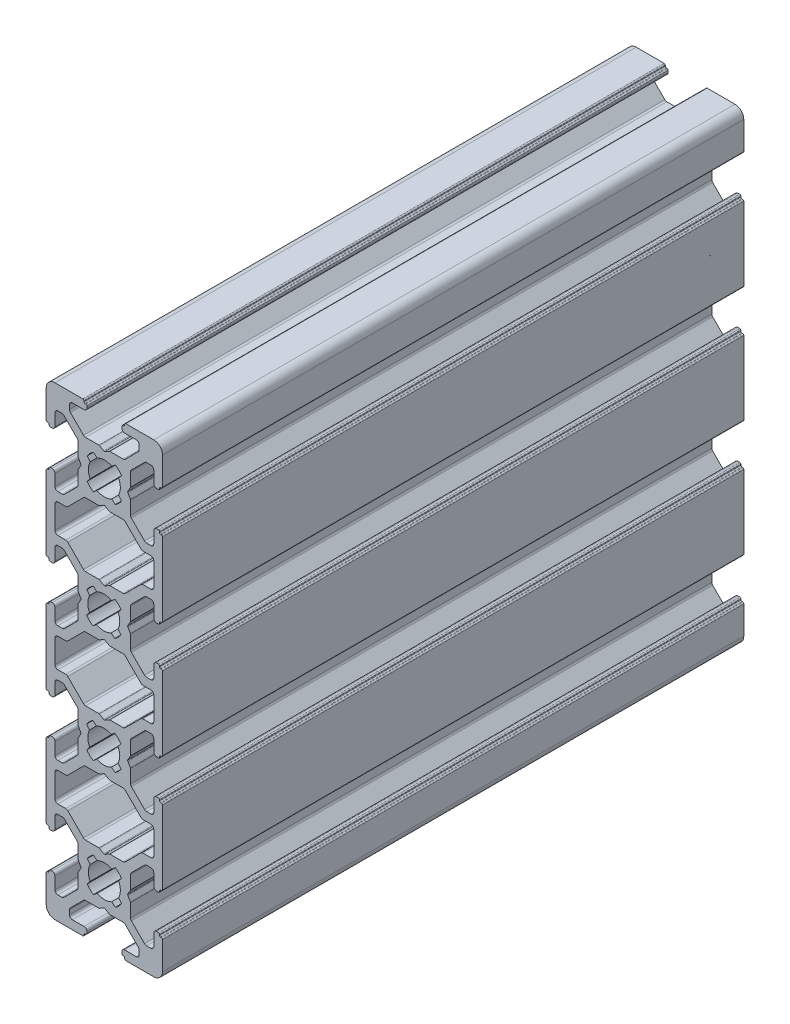
from build123d import *

# Parameters (mm, degrees)
EXTRUDE_1_DEPTH = 100


with BuildPart() as part:
    # Эскиз1 → Бобышка-Вытянуть1 (new body)
    with BuildSketch(Plane.XY):
        with BuildLine():
            Line((4.499999535, -3.232230546), (4.499999535, -0.95359075))
            ThreePointArc((4.499999535, -0.95359075), (4.4931847, -0.901826942), (4.473204617, -0.853590752))
            Line((4.473204617, -0.853590752), (4.038119091, -0.100000495))
            ThreePointArc((4.038119091, -0.100000495), (4.01132417, -4.91e-07), (4.038119086, 0.099999515))
            Line((4.038119086, 0.099999515), (4.473204622, 0.853589873))
            ThreePointArc((4.473204622, 0.853589873), (4.493184702, 0.901826059), (4.499999535, 0.953589862))
            Line((4.499999535, 0.953589862), (4.499999535, 3.232229658))
            ThreePointArc((4.499999535, 3.232229658), (4.538059693, 3.423571193), (4.646445866, 3.585782771))
            Line((4.646445866, 3.585782771), (6.914212891, 5.853553365))
            ThreePointArc((6.914212891, 5.853553365), (7.076424662, 5.961939944), (7.26776656, 6.000000253))
            Line((7.26776656, 6.000000253), (7.99999922, 6.000000253))
            ThreePointArc((7.99999922, 6.000000253), (8.353552705, 5.853553604), (8.499999354, 5.500000119))
            Line((8.499999354, 5.500000119), (8.499999354, 3.499999514))
            ThreePointArc((8.499999354, 3.499999514), (8.646445963, 3.146446123), (8.999999354, 2.999999514))
            Line((8.999999354, 2.999999514), (9.299998864, 2.999999514))
            ThreePointArc((9.299998864, 2.999999514), (9.44142022, 3.058578158), (9.499998864, 3.199999514))
            Line((9.499998864, 3.199999514), (9.499998864, 3.299999514))
            ThreePointArc((9.499998864, 3.299999514), (9.558577631, 3.441420994), (9.699999215, 3.499999514))
            Line((9.699999215, 3.499999514), (9.799999215, 3.499999339))
            ThreePointArc((9.799999215, 3.499999339), (9.941420798, 3.558577858), (9.999999566, 3.699999339))
            Line((9.999999566, 3.699999339), (9.999999566, 9.999999514))
            Line((9.999999566, 9.999999514), (9.999999566, 16.349999199))
            ThreePointArc((9.999999566, 16.349999199), (9.941420922, 16.491420555), (9.799999566, 16.549999199))
            Line((9.799999566, 16.549999199), (9.699999566, 16.549999199))
            ThreePointArc((9.699999566, 16.549999199), (9.558578154, 16.608577898), (9.499999566, 16.749999356))
            Line((9.499999566, 16.749999356), (9.499999645, 16.849999356))
            ThreePointArc((9.499999645, 16.849999356), (9.441421057, 16.991420815), (9.299999645, 17.049999514))
            Line((9.299999645, 17.049999514), (9.000000135, 17.049999514))
            ThreePointArc((9.000000135, 17.049999514), (8.646446744, 16.903552905), (8.500000135, 16.549999514))
            Line((8.500000135, 16.549999514), (8.500000135, 14.500000172))
            ThreePointArc((8.500000135, 14.500000172), (8.353553486, 14.146446686), (8.000000001, 14.000000038))
            Line((8.000000001, 14.000000038), (7.267765297, 14.000000038))
            ThreePointArc((7.267765297, 14.000000038), (7.076423399, 14.038060347), (6.914211628, 14.146446925))
            Line((6.914211628, 14.146446925), (4.646445866, 16.414216257))
            ThreePointArc((4.646445866, 16.414216257), (4.538059693, 16.576427835), (4.499999535, 16.76776937))
            Line((4.499999535, 16.76776937), (4.499999535, 19.046409166))
            ThreePointArc((4.499999535, 19.046409166), (4.493184702, 19.098172969), (4.473204622, 19.146409155))
            Line((4.473204622, 19.146409155), (4.038119086, 19.899999513))
            ThreePointArc((4.038119086, 19.899999513), (4.018139004, 19.948235705), (4.01132417, 19.999999514))
            ThreePointArc((4.01132417, 19.999999514), (4.018139004, 20.051763323), (4.038119086, 20.099999515))
            Line((4.038119086, 20.099999515), (4.473204615, 20.853589862))
            ThreePointArc((4.473204615, 20.853589862), (4.493184695, 20.901826048), (4.499999528, 20.953589851))
            Line((4.499999528, 20.953589851), (4.499999528, 23.232229647))
            ThreePointArc((4.499999528, 23.232229647), (4.538059687, 23.423571182), (4.64644586, 23.58578276))
            Line((4.64644586, 23.58578276), (6.914212884, 25.853553354))
            ThreePointArc((6.914212884, 25.853553354), (7.076424655, 25.961939932), (7.267766553, 26.000000241))
            Line((7.267766553, 26.000000241), (7.99999922, 26.000000241))
            ThreePointArc((7.99999922, 26.000000241), (8.353552705, 25.853553593), (8.499999354, 25.500000107))
            Line((8.499999354, 25.500000107), (8.499999354, 23.499999514))
            ThreePointArc((8.499999354, 23.499999514), (8.646445963, 23.146446123), (8.999999354, 22.999999514))
            Line((8.999999354, 22.999999514), (9.299998864, 22.999999514))
            ThreePointArc((9.299998864, 22.999999514), (9.44142022, 23.058578158), (9.499998864, 23.199999514))
            Line((9.499998864, 23.199999514), (9.499998864, 23.299999514))
            ThreePointArc((9.499998864, 23.299999514), (9.558577631, 23.441420994), (9.699999215, 23.499999514))
            Line((9.699999215, 23.499999514), (9.799999215, 23.499999339))
            ThreePointArc((9.799999215, 23.499999339), (9.941420798, 23.558577858), (9.999999566, 23.699999339))
            Line((9.999999566, 23.699999339), (9.999999566, 36.300000176))
            ThreePointArc((9.999999566, 36.300000176), (9.941420798, 36.441421656), (9.799999215, 36.500000176))
            Line((9.799999215, 36.500000176), (9.699999215, 36.5))
            ThreePointArc((9.699999215, 36.5), (9.558577631, 36.55857852), (9.499998864, 36.7))
            Line((9.499998864, 36.7), (9.499998864, 36.8))
            ThreePointArc((9.499998864, 36.8), (9.44142022, 36.941421356), (9.299998864, 37))
            Line((9.299998864, 37), (8.999999354, 37))
            ThreePointArc((8.999999354, 37), (8.646445963, 36.853553391), (8.499999354, 36.5))
            Line((8.499999354, 36.5), (8.499999354, 34.499999407))
            ThreePointArc((8.499999354, 34.499999407), (8.353552705, 34.146445921), (7.99999922, 33.999999273))
            Line((7.99999922, 33.999999273), (7.267766553, 33.999999273))
            ThreePointArc((7.267766553, 33.999999273), (7.076424655, 34.038059582), (6.914212884, 34.14644616))
            Line((6.914212884, 34.14644616), (4.64644586, 36.414216754))
            ThreePointArc((4.64644586, 36.414216754), (4.538059687, 36.576428332), (4.499999528, 36.767769867))
            Line((4.499999528, 36.767769867), (4.499999528, 39.046409663))
            ThreePointArc((4.499999528, 39.046409663), (4.493184695, 39.098173466), (4.473204615, 39.146409652))
            Line((4.473204615, 39.146409652), (4.038119086, 39.899999999))
            ThreePointArc((4.038119086, 39.899999999), (4.018139004, 39.948236191), (4.01132417, 40))
            ThreePointArc((4.01132417, 40), (4.018139004, 40.051763809), (4.038119086, 40.100000001))
            Line((4.038119086, 40.100000001), (4.473204622, 40.853590359))
            ThreePointArc((4.473204622, 40.853590359), (4.493184702, 40.901826545), (4.499999535, 40.953590348))
            Line((4.499999535, 40.953590348), (4.499999535, 43.232230144))
            ThreePointArc((4.499999535, 43.232230144), (4.538059693, 43.423571679), (4.646445866, 43.585783257))
            Line((4.646445866, 43.585783257), (6.914211628, 45.853552589))
            ThreePointArc((6.914211628, 45.853552589), (7.076423399, 45.961939167), (7.267765297, 45.999999476))
            Line((7.267765297, 45.999999476), (8.000000001, 45.999999476))
            ThreePointArc((8.000000001, 45.999999476), (8.353553486, 45.853552828), (8.500000135, 45.499999342))
            Line((8.500000135, 45.499999342), (8.500000135, 43.45))
            ThreePointArc((8.500000135, 43.45), (8.646446744, 43.096446609), (9.000000135, 42.95))
            Line((9.000000135, 42.95), (9.299999645, 42.95))
            ThreePointArc((9.299999645, 42.95), (9.441421057, 43.0085787), (9.499999645, 43.150000158))
            Line((9.499999645, 43.150000158), (9.499999566, 43.250000158))
            ThreePointArc((9.499999566, 43.250000158), (9.558578154, 43.391421616), (9.699999566, 43.450000315))
            Line((9.699999566, 43.450000315), (9.799999566, 43.450000315))
            ThreePointArc((9.799999566, 43.450000315), (9.941420922, 43.508578959), (9.999999566, 43.650000315))
            Line((9.999999566, 43.650000315), (9.999999566, 50))
            Line((9.999999566, 50), (9.999999566, 56.300000176))
            ThreePointArc((9.999999566, 56.300000176), (9.941420798, 56.441421656), (9.799999215, 56.500000176))
            Line((9.799999215, 56.500000176), (9.699999215, 56.5))
            ThreePointArc((9.699999215, 56.5), (9.558577631, 56.55857852), (9.499998864, 56.7))
            Line((9.499998864, 56.7), (9.499998864, 56.8))
            ThreePointArc((9.499998864, 56.8), (9.44142022, 56.941421356), (9.299998864, 57))
            Line((9.299998864, 57), (8.999999354, 57))
            ThreePointArc((8.999999354, 57), (8.646445963, 56.853553391), (8.499999354, 56.5))
            Line((8.499999354, 56.5), (8.499999354, 54.499999395))
            ThreePointArc((8.499999354, 54.499999395), (8.353552705, 54.14644591), (7.99999922, 53.999999261))
            Line((7.99999922, 53.999999261), (7.26776656, 53.999999261))
            ThreePointArc((7.26776656, 53.999999261), (7.076424662, 54.03805957), (6.914212891, 54.146446149))
            Line((6.914212891, 54.146446149), (4.646445866, 56.414216743))
            ThreePointArc((4.646445866, 56.414216743), (4.538059693, 56.576428321), (4.499999535, 56.767769856))
            Line((4.499999535, 56.767769856), (4.499999535, 59.046409652))
            ThreePointArc((4.499999535, 59.046409652), (4.493184702, 59.098173455), (4.473204622, 59.146409641))
            Line((4.473204622, 59.146409641), (4.038119086, 59.899999999))
            ThreePointArc((4.038119086, 59.899999999), (4.01132417, 60.000000005), (4.038119091, 60.100000009))
            Line((4.038119091, 60.100000009), (4.473204617, 60.853590266))
            ThreePointArc((4.473204617, 60.853590266), (4.4931847, 60.901826456), (4.499999535, 60.953590264))
            Line((4.499999535, 60.953590264), (4.499999535, 63.23223006))
            ThreePointArc((4.499999535, 63.23223006), (4.538059689, 63.423571583), (4.646445849, 63.585783155))
            Line((4.646445849, 63.585783155), (6.91421126, 65.853552357))
            ThreePointArc((6.91421126, 65.853552357), (7.076423037, 65.961938948), (7.267764946, 65.999999261))
            Line((7.267764946, 65.999999261), (7.999999354, 65.999999261))
            ThreePointArc((7.999999354, 65.999999261), (8.353552744, 65.853552652), (8.499999354, 65.499999261))
            Line((8.499999354, 65.499999261), (8.499999354, 63.5))
            ThreePointArc((8.499999354, 63.5), (8.646445963, 63.146446609), (8.999999354, 63))
            Line((8.999999354, 63), (9.299998864, 63))
            ThreePointArc((9.299998864, 63), (9.44142022, 63.058578644), (9.499998864, 63.2))
            Line((9.499998864, 63.2), (9.499998864, 63.3))
            ThreePointArc((9.499998864, 63.3), (9.558577631, 63.44142148), (9.699999215, 63.5))
            Line((9.699999215, 63.5), (9.799999215, 63.499999824))
            ThreePointArc((9.799999215, 63.499999824), (9.941420798, 63.558578344), (9.999999566, 63.699999824))
            Line((9.999999566, 63.699999824), (9.999999566, 68.500000027))
            ThreePointArc((9.999999566, 68.500000027), (9.560659745, 69.56066018), (8.499999593, 70))
            Line((8.499999593, 70), (3.699999104, 70))
            ThreePointArc((3.699999104, 70), (3.558577748, 69.941421356), (3.499999104, 69.8))
            Line((3.499999104, 69.8), (3.499999104, 69.7))
            ThreePointArc((3.499999104, 69.7), (3.441420542, 69.558578725), (3.299999335, 69.5))
            Line((3.299999335, 69.5), (3.199999335, 69.499999885))
            ThreePointArc((3.199999335, 69.499999885), (3.058578128, 69.441421159), (2.999999566, 69.299999885))
            Line((2.999999566, 69.299999885), (2.999999566, 69.000001846))
            ThreePointArc((2.999999566, 69.000001846), (3.146446175, 68.646448455), (3.499999566, 68.500001846))
            Line((3.499999566, 68.500001846), (5.499999432, 68.500001846))
            ThreePointArc((5.499999432, 68.500001846), (5.853552917, 68.353555197), (5.999999566, 68.000001712))
            Line((5.999999566, 68.000001712), (5.999999566, 67.267766328))
            ThreePointArc((5.999999566, 67.267766328), (5.961940007, 67.076426242), (5.853555452, 66.914215433))
            Line((5.853555452, 66.914215433), (3.585869317, 64.646497282))
            ThreePointArc((3.585869317, 64.646497282), (3.423656777, 64.538109086), (3.23231343, 64.500048177))
            Line((3.23231343, 64.500048177), (0.953673634, 64.500048177))
            ThreePointArc((0.953673634, 64.500048177), (0.901909826, 64.493233342), (0.853673636, 64.473253259))
            Line((0.853673636, 64.473253259), (0.099999543, 64.03811933))
            ThreePointArc((0.099999543, 64.03811933), (-4.69e-07, 64.011324409), (-0.100000481, 64.038119334))
            Line((-0.100000481, 64.038119334), (-0.853674499, 64.473253255))
            ThreePointArc((-0.853674499, 64.473253255), (-0.901910692, 64.493233342), (-0.953674503, 64.500048177))
            Line((-0.953674503, 64.500048177), (-3.232314299, 64.500048177))
            ThreePointArc((-3.232314299, 64.500048177), (-3.423657646, 64.538109086), (-3.585870185, 64.646497282))
            Line((-3.585870185, 64.646497282), (-5.853556321, 66.914215433))
            ThreePointArc((-5.853556321, 66.914215433), (-5.961940876, 67.076426242), (-6.000000434, 67.267766328))
            Line((-6.000000434, 67.267766328), (-6.000000434, 68.000000007))
            ThreePointArc((-6.000000434, 68.000000007), (-5.853553825, 68.353553397), (-5.500000434, 68.500000007))
            Line((-5.500000434, 68.500000007), (-3.500000434, 68.500000007))
            ThreePointArc((-3.500000434, 68.500000007), (-3.146447044, 68.646446616), (-3.000000434, 69.000000007))
            Line((-3.000000434, 69.000000007), (-3.000000434, 69.299998046))
            ThreePointArc((-3.000000434, 69.299998046), (-3.058579078, 69.441419402), (-3.200000434, 69.499998046))
            Line((-3.200000434, 69.499998046), (-3.300000434, 69.499998046))
            ThreePointArc((-3.300000434, 69.499998046), (-3.441422136, 69.558577035), (-3.500000434, 69.699999023))
            Line((-3.500000434, 69.699999023), (-3.499999946, 69.799999023))
            ThreePointArc((-3.499999946, 69.799999023), (-3.558578244, 69.941421011), (-3.699999946, 70))
            Line((-3.699999946, 70), (-8.500000434, 70))
            ThreePointArc((-8.500000434, 70), (-9.560660606, 69.560660172), (-10.000000434, 68.5))
            Line((-10.000000434, 68.5), (-10.000000434, 63.699999824))
            ThreePointArc((-10.000000434, 63.699999824), (-9.941421666, 63.558578344), (-9.800000083, 63.499999824))
            Line((-9.800000083, 63.499999824), (-9.700000083, 63.5))
            ThreePointArc((-9.700000083, 63.5), (-9.5585785, 63.44142148), (-9.499999732, 63.3))
            Line((-9.499999732, 63.3), (-9.499999732, 63.2))
            ThreePointArc((-9.499999732, 63.2), (-9.441421088, 63.058578644), (-9.299999732, 63))
            Line((-9.299999732, 63), (-9.000000223, 63))
            ThreePointArc((-9.000000223, 63), (-8.646446832, 63.146446609), (-8.500000223, 63.5))
            Line((-8.500000223, 63.5), (-8.500000223, 65.549999866))
            ThreePointArc((-8.500000223, 65.549999866), (-8.353553574, 65.903553351), (-8.000000089, 66.05))
            Line((-8.000000089, 66.05), (-7.31776647, 66.05))
            ThreePointArc((-7.31776647, 66.05), (-7.126424561, 66.011939686), (-6.964212784, 65.903553095))
            Line((-6.964212784, 65.903553095), (-4.646446717, 63.585783155))
            ThreePointArc((-4.646446717, 63.585783155), (-4.538060557, 63.423571583), (-4.500000403, 63.23223006))
            Line((-4.500000403, 63.23223006), (-4.500000403, 60.953590264))
            ThreePointArc((-4.500000403, 60.953590264), (-4.493185569, 60.901826456), (-4.473205485, 60.853590266))
            Line((-4.473205485, 60.853590266), (-4.038119917, 60.099999935))
            ThreePointArc((-4.038119917, 60.099999935), (-4.011324996, 59.999999923), (-4.038119921, 59.899999911))
            Line((-4.038119921, 59.899999911), (-4.473205482, 59.146409656))
            ThreePointArc((-4.473205482, 59.146409656), (-4.493185568, 59.098173463), (-4.500000403, 59.046409652))
            Line((-4.500000403, 59.046409652), (-4.500000403, 56.767769856))
            ThreePointArc((-4.500000403, 56.767769856), (-4.538060562, 56.576428321), (-4.646446735, 56.414216743))
            Line((-4.646446735, 56.414216743), (-6.8642131, 54.196446888))
            ThreePointArc((-6.8642131, 54.196446888), (-7.02642487, 54.088060309), (-7.217766768, 54.05))
            Line((-7.217766768, 54.05), (-8.000000925, 54.05))
            ThreePointArc((-8.000000925, 54.05), (-8.353554315, 54.196446609), (-8.500000925, 54.55))
            Line((-8.500000925, 54.55), (-8.500000925, 56.5))
            ThreePointArc((-8.500000925, 56.5), (-8.646447534, 56.853553391), (-9.000000925, 57))
            Line((-9.000000925, 57), (-9.300000434, 57))
            ThreePointArc((-9.300000434, 57), (-9.441421791, 56.941421356), (-9.500000434, 56.8))
            Line((-9.500000434, 56.8), (-9.500000434, 56.7))
            ThreePointArc((-9.500000434, 56.7), (-9.558579078, 56.558578644), (-9.700000434, 56.5))
            Line((-9.700000434, 56.5), (-9.800000434, 56.5))
            ThreePointArc((-9.800000434, 56.5), (-9.941421791, 56.441421356), (-10.000000434, 56.3))
            Line((-10.000000434, 56.3), (-10.000000434, 49.999999757))
            Line((-10.000000434, 49.999999757), (-10.000000434, 43.650000315))
            ThreePointArc((-10.000000434, 43.650000315), (-9.941421791, 43.508578959), (-9.800000434, 43.450000315))
            Line((-9.800000434, 43.450000315), (-9.700000434, 43.450000315))
            ThreePointArc((-9.700000434, 43.450000315), (-9.558579022, 43.391421616), (-9.500000434, 43.250000158))
            Line((-9.500000434, 43.250000158), (-9.500000513, 43.150000158))
            ThreePointArc((-9.500000513, 43.150000158), (-9.441421925, 43.008578699), (-9.300000513, 42.95))
            Line((-9.300000513, 42.95), (-9.000001003, 42.95))
            ThreePointArc((-9.000001003, 42.95), (-8.646447613, 43.096446609), (-8.500001003, 43.45))
            Line((-8.500001003, 43.45), (-8.500001003, 45.499999476))
            ThreePointArc((-8.500001003, 45.499999476), (-8.353554394, 45.853552867), (-8.000001003, 45.999999476))
            Line((-8.000001003, 45.999999476), (-7.267766166, 45.999999476))
            ThreePointArc((-7.267766166, 45.999999476), (-7.076424268, 45.961939167), (-6.914212497, 45.853552589))
            Line((-6.914212497, 45.853552589), (-4.646446735, 43.585783257))
            ThreePointArc((-4.646446735, 43.585783257), (-4.538060562, 43.423571679), (-4.500000403, 43.232230144))
            Line((-4.500000403, 43.232230144), (-4.500000403, 40.953590348))
            ThreePointArc((-4.500000403, 40.953590348), (-4.493185569, 40.901826541), (-4.473205486, 40.853590352))
            Line((-4.473205486, 40.853590352), (-4.038119916, 40.100000008))
            ThreePointArc((-4.038119916, 40.100000008), (-4.018139831, 40.051763813), (-4.011324996, 40))
            ThreePointArc((-4.011324996, 40), (-4.018139831, 39.948236187), (-4.038119916, 39.899999992))
            Line((-4.038119916, 39.899999992), (-4.473205486, 39.146409648))
            ThreePointArc((-4.473205486, 39.146409648), (-4.493185569, 39.098173459), (-4.500000403, 39.046409652))
            Line((-4.500000403, 39.046409652), (-4.500000403, 36.767769856))
            ThreePointArc((-4.500000403, 36.767769856), (-4.538060562, 36.576428321), (-4.646446735, 36.414216743))
            Line((-4.646446735, 36.414216743), (-6.8642131, 34.196446888))
            ThreePointArc((-6.8642131, 34.196446888), (-7.02642487, 34.088060309), (-7.217766768, 34.05))
            Line((-7.217766768, 34.05), (-8.000000925, 34.05))
            ThreePointArc((-8.000000925, 34.05), (-8.353554315, 34.196446609), (-8.500000925, 34.55))
            Line((-8.500000925, 34.55), (-8.500000925, 36.5))
            ThreePointArc((-8.500000925, 36.5), (-8.646447534, 36.853553391), (-9.000000925, 37))
            Line((-9.000000925, 37), (-9.300000434, 37))
            ThreePointArc((-9.300000434, 37), (-9.441421791, 36.941421356), (-9.500000434, 36.8))
            Line((-9.500000434, 36.8), (-9.500000434, 36.7))
            ThreePointArc((-9.500000434, 36.7), (-9.558579078, 36.558578644), (-9.700000434, 36.5))
            Line((-9.700000434, 36.5), (-9.800000434, 36.5))
            ThreePointArc((-9.800000434, 36.5), (-9.941421791, 36.441421356), (-10.000000434, 36.3))
            Line((-10.000000434, 36.3), (-10.000000434, 23.699999514))
            ThreePointArc((-10.000000434, 23.699999514), (-9.941421791, 23.558578158), (-9.800000434, 23.499999514))
            Line((-9.800000434, 23.499999514), (-9.700000434, 23.499999514))
            ThreePointArc((-9.700000434, 23.499999514), (-9.558579078, 23.44142087), (-9.500000434, 23.299999514))
            Line((-9.500000434, 23.299999514), (-9.500000434, 23.199999514))
            ThreePointArc((-9.500000434, 23.199999514), (-9.441421791, 23.058578158), (-9.300000434, 22.999999514))
            Line((-9.300000434, 22.999999514), (-9.000000925, 22.999999514))
            ThreePointArc((-9.000000925, 22.999999514), (-8.646447534, 23.146446123), (-8.500000925, 23.499999514))
            Line((-8.500000925, 23.499999514), (-8.500000925, 25.449999514))
            ThreePointArc((-8.500000925, 25.449999514), (-8.353554315, 25.803552905), (-8.000000925, 25.949999514))
            Line((-8.000000925, 25.949999514), (-7.217766768, 25.949999514))
            ThreePointArc((-7.217766768, 25.949999514), (-7.02642487, 25.911939205), (-6.8642131, 25.803552626))
            Line((-6.8642131, 25.803552626), (-4.646446735, 23.585782771))
            ThreePointArc((-4.646446735, 23.585782771), (-4.538060562, 23.423571193), (-4.500000403, 23.232229658))
            Line((-4.500000403, 23.232229658), (-4.500000403, 20.953589862))
            ThreePointArc((-4.500000403, 20.953589862), (-4.493185569, 20.901826055), (-4.473205486, 20.853589866))
            Line((-4.473205486, 20.853589866), (-4.038119916, 20.099999522))
            ThreePointArc((-4.038119916, 20.099999522), (-4.018139831, 20.051763327), (-4.011324996, 19.999999514))
            ThreePointArc((-4.011324996, 19.999999514), (-4.018139831, 19.948235701), (-4.038119916, 19.899999506))
            Line((-4.038119916, 19.899999506), (-4.473205486, 19.146409163))
            ThreePointArc((-4.473205486, 19.146409163), (-4.493185569, 19.098172973), (-4.500000403, 19.046409166))
            Line((-4.500000403, 19.046409166), (-4.500000403, 16.76776937))
            ThreePointArc((-4.500000403, 16.76776937), (-4.538060562, 16.576427835), (-4.646446735, 16.414216257))
            Line((-4.646446735, 16.414216257), (-6.914212497, 14.146446925))
            ThreePointArc((-6.914212497, 14.146446925), (-7.076424268, 14.038060347), (-7.267766166, 14.000000038))
            Line((-7.267766166, 14.000000038), (-8.000001003, 14.000000038))
            ThreePointArc((-8.000001003, 14.000000038), (-8.353554394, 14.146446647), (-8.500001003, 14.500000038))
            Line((-8.500001003, 14.500000038), (-8.500001003, 16.549999514))
            ThreePointArc((-8.500001003, 16.549999514), (-8.646447613, 16.903552905), (-9.000001003, 17.049999514))
            Line((-9.000001003, 17.049999514), (-9.300000513, 17.049999514))
            ThreePointArc((-9.300000513, 17.049999514), (-9.441421925, 16.991420815), (-9.500000513, 16.849999356))
            Line((-9.500000513, 16.849999356), (-9.500000434, 16.749999356))
            ThreePointArc((-9.500000434, 16.749999356), (-9.558579022, 16.608577898), (-9.700000434, 16.549999199))
            Line((-9.700000434, 16.549999199), (-9.800000434, 16.549999199))
            ThreePointArc((-9.800000434, 16.549999199), (-9.941421791, 16.491420555), (-10.000000434, 16.349999199))
            Line((-10.000000434, 16.349999199), (-10.000000434, 9.999999757))
            Line((-10.000000434, 9.999999757), (-10.000000434, 3.699999514))
            ThreePointArc((-10.000000434, 3.699999514), (-9.941421791, 3.558578158), (-9.800000434, 3.499999514))
            Line((-9.800000434, 3.499999514), (-9.700000434, 3.499999514))
            ThreePointArc((-9.700000434, 3.499999514), (-9.558579078, 3.44142087), (-9.500000434, 3.299999514))
            Line((-9.500000434, 3.299999514), (-9.500000434, 3.199999514))
            ThreePointArc((-9.500000434, 3.199999514), (-9.441421791, 3.058578158), (-9.300000434, 2.999999514))
            Line((-9.300000434, 2.999999514), (-9.000000925, 2.999999514))
            ThreePointArc((-9.000000925, 2.999999514), (-8.646447534, 3.146446123), (-8.500000925, 3.499999514))
            Line((-8.500000925, 3.499999514), (-8.500000925, 5.449999514))
            ThreePointArc((-8.500000925, 5.449999514), (-8.353554315, 5.803552905), (-8.000000925, 5.949999514))
            Line((-8.000000925, 5.949999514), (-7.217766768, 5.949999514))
            ThreePointArc((-7.217766768, 5.949999514), (-7.02642487, 5.911939205), (-6.8642131, 5.803552626))
            Line((-6.8642131, 5.803552626), (-4.646446735, 3.585782771))
            ThreePointArc((-4.646446735, 3.585782771), (-4.538060562, 3.423571193), (-4.500000403, 3.232229658))
            Line((-4.500000403, 3.232229658), (-4.500000403, 0.953589862))
            ThreePointArc((-4.500000403, 0.953589862), (-4.493185568, 0.901826051), (-4.473205482, 0.853589858))
            Line((-4.473205482, 0.853589858), (-4.038119921, 0.099999603))
            ThreePointArc((-4.038119921, 0.099999603), (-4.011324996, -4.09e-07), (-4.038119917, -0.100000421))
            Line((-4.038119917, -0.100000421), (-4.473205485, -0.853590752))
            ThreePointArc((-4.473205485, -0.853590752), (-4.493185569, -0.901826942), (-4.500000403, -0.95359075))
            Line((-4.500000403, -0.95359075), (-4.500000403, -3.232230546))
            ThreePointArc((-4.500000403, -3.232230546), (-4.538060557, -3.423572069), (-4.646446717, -3.585783641))
            Line((-4.646446717, -3.585783641), (-6.964212784, -5.903553581))
            ThreePointArc((-6.964212784, -5.903553581), (-7.126424561, -6.011940172), (-7.31776647, -6.050000486))
            Line((-7.31776647, -6.050000486), (-8.000000089, -6.050000486))
            ThreePointArc((-8.000000089, -6.050000486), (-8.353553574, -5.903553837), (-8.500000223, -5.550000352))
            Line((-8.500000223, -5.550000352), (-8.500000223, -3.500000486))
            ThreePointArc((-8.500000223, -3.500000486), (-8.646446832, -3.146447095), (-9.000000223, -3.000000486))
            Line((-9.000000223, -3.000000486), (-9.299999732, -3.000000486))
            ThreePointArc((-9.299999732, -3.000000486), (-9.441421088, -3.05857913), (-9.499999732, -3.200000486))
            Line((-9.499999732, -3.200000486), (-9.499999732, -3.300000486))
            ThreePointArc((-9.499999732, -3.300000486), (-9.5585785, -3.441421966), (-9.700000083, -3.500000486))
            Line((-9.700000083, -3.500000486), (-9.800000083, -3.50000031))
            ThreePointArc((-9.800000083, -3.50000031), (-9.941421666, -3.55857883), (-10.000000434, -3.70000031))
            Line((-10.000000434, -3.70000031), (-10.000000434, -8.500000486))
            ThreePointArc((-10.000000434, -8.500000486), (-9.560660606, -9.560660658), (-8.500000434, -10.000000486))
            Line((-8.500000434, -10.000000486), (-3.699999946, -10.000000486))
            ThreePointArc((-3.699999946, -10.000000486), (-3.558578244, -9.941421497), (-3.499999946, -9.799999509))
            Line((-3.499999946, -9.799999509), (-3.500000434, -9.699999509))
            ThreePointArc((-3.500000434, -9.699999509), (-3.441422136, -9.558577521), (-3.300000434, -9.499998532))
            Line((-3.300000434, -9.499998532), (-3.200000434, -9.499998532))
            ThreePointArc((-3.200000434, -9.499998532), (-3.058579078, -9.441419888), (-3.000000434, -9.299998532))
            Line((-3.000000434, -9.299998532), (-3.000000434, -9.000000493))
            ThreePointArc((-3.000000434, -9.000000493), (-3.146447044, -8.646447102), (-3.500000434, -8.500000493))
            Line((-3.500000434, -8.500000493), (-5.500000434, -8.500000493))
            ThreePointArc((-5.500000434, -8.500000493), (-5.853553825, -8.353553883), (-6.000000434, -8.000000493))
            Line((-6.000000434, -8.000000493), (-6.000000434, -7.267766814))
            ThreePointArc((-6.000000434, -7.267766814), (-5.961940876, -7.076426728), (-5.853556321, -6.914215919))
            Line((-5.853556321, -6.914215919), (-3.585870185, -4.646497768))
            ThreePointArc((-3.585870185, -4.646497768), (-3.423657646, -4.538109572), (-3.232314299, -4.500048663))
            Line((-3.232314299, -4.500048663), (-0.953674503, -4.500048663))
            ThreePointArc((-0.953674503, -4.500048663), (-0.901910692, -4.493233828), (-0.853674499, -4.473253741))
            Line((-0.853674499, -4.473253741), (-0.100000481, -4.03811982))
            ThreePointArc((-0.100000481, -4.03811982), (-4.69e-07, -4.011324895), (0.099999543, -4.038119816))
            Line((0.099999543, -4.038119816), (0.853673636, -4.473253745))
            ThreePointArc((0.853673636, -4.473253745), (0.901909826, -4.493233828), (0.953673634, -4.500048663))
            Line((0.953673634, -4.500048663), (3.23231343, -4.500048663))
            ThreePointArc((3.23231343, -4.500048663), (3.423656777, -4.538109572), (3.585869317, -4.646497768))
            Line((3.585869317, -4.646497768), (5.853555452, -6.914215919))
            ThreePointArc((5.853555452, -6.914215919), (5.961940007, -7.076426728), (5.999999566, -7.267766814))
            Line((5.999999566, -7.267766814), (5.999999566, -8.000002198))
            ThreePointArc((5.999999566, -8.000002198), (5.853552917, -8.353555683), (5.499999432, -8.500002332))
            Line((5.499999432, -8.500002332), (3.499999566, -8.500002332))
            ThreePointArc((3.499999566, -8.500002332), (3.146446175, -8.646448941), (2.999999566, -9.000002332))
            Line((2.999999566, -9.000002332), (2.999999566, -9.300000371))
            ThreePointArc((2.999999566, -9.300000371), (3.058578128, -9.441421645), (3.199999335, -9.500000371))
            Line((3.199999335, -9.500000371), (3.299999335, -9.500000486))
            ThreePointArc((3.299999335, -9.500000486), (3.441420542, -9.558579211), (3.499999104, -9.700000486))
            Line((3.499999104, -9.700000486), (3.499999104, -9.800000486))
            ThreePointArc((3.499999104, -9.800000486), (3.558577748, -9.941421842), (3.699999104, -10.000000486))
            Line((3.699999104, -10.000000486), (8.499999593, -10.000000486))
            ThreePointArc((8.499999593, -10.000000486), (9.560659745, -9.560660666), (9.999999566, -8.500000513))
            Line((9.999999566, -8.500000513), (9.999999566, -3.70000031))
            ThreePointArc((9.999999566, -3.70000031), (9.941420798, -3.55857883), (9.799999215, -3.50000031))
            Line((9.799999215, -3.50000031), (9.699999215, -3.500000486))
            ThreePointArc((9.699999215, -3.500000486), (9.558577631, -3.441421966), (9.499998864, -3.300000486))
            Line((9.499998864, -3.300000486), (9.499998864, -3.200000486))
            ThreePointArc((9.499998864, -3.200000486), (9.44142022, -3.05857913), (9.299998864, -3.000000486))
            Line((9.299998864, -3.000000486), (8.999999354, -3.000000486))
            ThreePointArc((8.999999354, -3.000000486), (8.646445963, -3.146447095), (8.499999354, -3.500000486))
            Line((8.499999354, -3.500000486), (8.499999354, -5.499999747))
            ThreePointArc((8.499999354, -5.499999747), (8.353552744, -5.853553138), (7.999999354, -5.999999747))
            Line((7.999999354, -5.999999747), (7.267764946, -5.999999747))
            ThreePointArc((7.267764946, -5.999999747), (7.076423037, -5.961939434), (6.91421126, -5.853552843))
            Line((6.91421126, -5.853552843), (4.646445849, -3.585783641))
            ThreePointArc((4.646445849, -3.585783641), (4.538059689, -3.423572069), (4.499999535, -3.232230546))
        make_face()
        with BuildLine():
            Line((-6.646447848, 7.499999514), (-8.000000223, 7.499999514))
            ThreePointArc((-8.000000223, 7.499999514), (-8.353553613, 7.646446123), (-8.500000223, 7.999999514))
            Line((-8.500000223, 7.999999514), (-8.500000223, 11.999999514))
            ThreePointArc((-8.500000223, 11.999999514), (-8.353553613, 12.353552905), (-8.000000223, 12.499999514))
            Line((-8.000000223, 12.499999514), (-6.646447848, 12.499999514))
            ThreePointArc((-6.646447848, 12.499999514), (-6.455102766, 12.538061142), (-6.292889305, 12.646451276))
            Line((-6.292889305, 12.646451276), (-3.585984629, 15.353434847))
            ThreePointArc((-3.585984629, 15.353434847), (-3.423771168, 15.461824981), (-3.232426086, 15.499886609))
            Line((-3.232426086, 15.499886609), (-0.95378629, 15.499886609))
            ThreePointArc((-0.95378629, 15.499886609), (-0.902022482, 15.506701443), (-0.853786292, 15.526681527))
            Line((-0.853786292, 15.526681527), (-0.100000412, 15.961879996))
            ThreePointArc((-0.100000412, 15.961879996), (-3.99e-07, 15.988674917), (0.099999612, 15.961879992))
            Line((0.099999612, 15.961879992), (0.853785417, 15.526681531))
            ThreePointArc((0.853785417, 15.526681531), (0.90202161, 15.506701444), (0.953785422, 15.499886609))
            Line((0.953785422, 15.499886609), (3.232425218, 15.499886609))
            ThreePointArc((3.232425218, 15.499886609), (3.4237703, 15.461824981), (3.58598376, 15.353434847))
            Line((3.58598376, 15.353434847), (6.292888157, 12.646451555))
            ThreePointArc((6.292888157, 12.646451555), (6.455101618, 12.538061422), (6.6464467, 12.499999794))
            Line((6.6464467, 12.499999794), (7.999999354, 12.499999794))
            ThreePointArc((7.999999354, 12.499999794), (8.353552744, 12.353553184), (8.499999354, 11.999999794))
            Line((8.499999354, 11.999999794), (8.499999354, 7.999999233))
            ThreePointArc((8.499999354, 7.999999233), (8.353552744, 7.646445842), (7.999999354, 7.499999233))
            Line((7.999999354, 7.499999233), (6.646446698, 7.499999233))
            ThreePointArc((6.646446698, 7.499999233), (6.455104805, 7.461938926), (6.292893037, 7.353552353))
            Line((6.292893037, 7.353552353), (3.585801994, 4.646457174))
            ThreePointArc((3.585801994, 4.646457174), (3.423590226, 4.538070602), (3.232248333, 4.500010295))
            Line((3.232248333, 4.500010295), (0.953608537, 4.500010295))
            ThreePointArc((0.953608537, 4.500010295), (0.901844726, 4.493195459), (0.853608533, 4.473215373))
            Line((0.853608533, 4.473215373), (0.099999612, 4.038119036))
            ThreePointArc((0.099999612, 4.038119036), (-3.99e-07, 4.011324111), (-0.100000412, 4.038119032))
            Line((-0.100000412, 4.038119032), (-0.853609408, 4.473215377))
            ThreePointArc((-0.853609408, 4.473215377), (-0.901845598, 4.49319546), (-0.953609406, 4.500010295))
            Line((-0.953609406, 4.500010295), (-3.232249202, 4.500010295))
            ThreePointArc((-3.232249202, 4.500010295), (-3.423591094, 4.538070602), (-3.585802862, 4.646457174))
            Line((-3.585802862, 4.646457174), (-6.292894187, 7.353552635))
            ThreePointArc((-6.292894187, 7.353552635), (-6.455105955, 7.461939207), (-6.646447848, 7.499999514))
        make_face(mode=Mode.SUBTRACT)
        with BuildLine():
            Line((2.445294989, -1.258185803), (2.947714602, -1.887055351))
            ThreePointArc((2.947714602, -1.887055351), (2.47487336, -2.47487416), (1.887054574, -2.947715431))
            Line((1.887054574, -2.947715431), (1.258185002, -2.445295848))
            ThreePointArc((1.258185002, -2.445295848), (-3.67e-07, -2.750000486), (-1.258185751, -2.445295909))
            Line((-1.258185751, -2.445295909), (-1.887055299, -2.947715523))
            ThreePointArc((-1.887055299, -2.947715523), (-2.474874108, -2.47487428), (-2.947715379, -1.887055494))
            Line((-2.947715379, -1.887055494), (-2.445295796, -1.258185922))
            ThreePointArc((-2.445295796, -1.258185922), (-2.750000434, -5.53e-07), (-2.445295858, 1.258184831))
            Line((-2.445295858, 1.258184831), (-2.947715471, 1.887054379))
            ThreePointArc((-2.947715471, 1.887054379), (-2.474874229, 2.474873188), (-1.887055443, 2.947714459))
            Line((-1.887055443, 2.947714459), (-1.25818587, 2.445294876))
            ThreePointArc((-1.25818587, 2.445294876), (-5.01e-07, 2.749999514), (1.258184883, 2.445294938))
            Line((1.258184883, 2.445294938), (1.887054431, 2.947714551))
            ThreePointArc((1.887054431, 2.947714551), (2.47487324, 2.474873308), (2.94771451, 1.887054522))
            Line((2.94771451, 1.887054522), (2.445294928, 1.25818495))
            ThreePointArc((2.445294928, 1.25818495), (2.749999566, -4.19e-07), (2.445294989, -1.258185803))
        make_face(mode=Mode.SUBTRACT)
        with BuildLine():
            Line((-1.358185848, 37.554704638), (-1.98705542, 37.052285055))
            ThreePointArc((-1.98705542, 37.052285055), (-2.574874206, 37.525126326), (-3.047715449, 38.112945135))
            Line((-3.047715449, 38.112945135), (-2.545295835, 38.741814683))
            ThreePointArc((-2.545295835, 38.741814683), (-2.849914783, 40.021701446), (-2.525134118, 41.296621188))
            Line((-2.525134118, 41.296621188), (-3.017566098, 41.933341787))
            ThreePointArc((-3.017566098, 41.933341787), (-2.524610435, 42.52413673), (-1.914473083, 42.992939847))
            Line((-1.914473083, 42.992939847), (-1.298066428, 42.475305601))
            ThreePointArc((-1.298066428, 42.475305601), (-0.033830766, 42.749203808), (1.21576391, 42.414801079))
            Line((1.21576391, 42.414801079), (1.856359905, 42.902180957))
            ThreePointArc((1.856359905, 42.902180957), (2.422338125, 42.426480642), (2.875764011, 41.842505386))
            Line((2.875764011, 41.842505386), (2.363942525, 41.221263772))
            ThreePointArc((2.363942525, 41.221263772), (2.649921817, 39.979318237), (2.34529495, 38.741814564))
            Line((2.34529495, 38.741814564), (2.847714533, 38.112944992))
            ThreePointArc((2.847714533, 38.112944992), (2.374873262, 37.525126206), (1.787054453, 37.052284963))
            Line((1.787054453, 37.052284963), (1.158184905, 37.554704577))
            ThreePointArc((1.158184905, 37.554704577), (-0.100000479, 37.25), (-1.358185848, 37.554704638))
        make_face(mode=Mode.SUBTRACT)
        with BuildLine():
            Line((3.232248333, 35.499989219), (0.953608537, 35.499989219))
            ThreePointArc((0.953608537, 35.499989219), (0.901844726, 35.506804055), (0.853608533, 35.526784141))
            Line((0.853608533, 35.526784141), (0.099999612, 35.961880478))
            ThreePointArc((0.099999612, 35.961880478), (-3.99e-07, 35.988675403), (-0.100000412, 35.961880482))
            Line((-0.100000412, 35.961880482), (-0.853609408, 35.526784137))
            ThreePointArc((-0.853609408, 35.526784137), (-0.901845598, 35.506804054), (-0.953609406, 35.499989219))
            Line((-0.953609406, 35.499989219), (-3.232249202, 35.499989219))
            ThreePointArc((-3.232249202, 35.499989219), (-3.423591094, 35.461928912), (-3.585802862, 35.35354234))
            Line((-3.585802862, 35.35354234), (-6.292894187, 32.646446879))
            ThreePointArc((-6.292894187, 32.646446879), (-6.455105955, 32.538060307), (-6.646447848, 32.5))
            Line((-6.646447848, 32.5), (-8.000000223, 32.5))
            ThreePointArc((-8.000000223, 32.5), (-8.353553613, 32.353553391), (-8.500000223, 32))
            Line((-8.500000223, 32), (-8.500000223, 27.999999514))
            ThreePointArc((-8.500000223, 27.999999514), (-8.353553613, 27.646446123), (-8.000000223, 27.499999514))
            Line((-8.000000223, 27.499999514), (-6.646447848, 27.499999514))
            ThreePointArc((-6.646447848, 27.499999514), (-6.455105955, 27.461939207), (-6.292894187, 27.353552635))
            Line((-6.292894187, 27.353552635), (-3.585802862, 24.646457174))
            ThreePointArc((-3.585802862, 24.646457174), (-3.423591094, 24.538070602), (-3.232249202, 24.500010295))
            Line((-3.232249202, 24.500010295), (-0.953609406, 24.500010295))
            ThreePointArc((-0.953609406, 24.500010295), (-0.901845598, 24.49319546), (-0.853609408, 24.473215377))
            Line((-0.853609408, 24.473215377), (-0.100000412, 24.038119032))
            ThreePointArc((-0.100000412, 24.038119032), (-3.99e-07, 24.011324111), (0.099999612, 24.038119036))
            Line((0.099999612, 24.038119036), (0.853608533, 24.473215373))
            ThreePointArc((0.853608533, 24.473215373), (0.901844726, 24.493195459), (0.953608537, 24.500010295))
            Line((0.953608537, 24.500010295), (3.232248333, 24.500010295))
            ThreePointArc((3.232248333, 24.500010295), (3.423590226, 24.538070602), (3.585801994, 24.646457174))
            Line((3.585801994, 24.646457174), (6.292893037, 27.353552353))
            ThreePointArc((6.292893037, 27.353552353), (6.455104805, 27.461938926), (6.646446698, 27.499999233))
            Line((6.646446698, 27.499999233), (7.999999354, 27.499999233))
            ThreePointArc((7.999999354, 27.499999233), (8.353552744, 27.646445842), (8.499999354, 27.999999233))
            Line((8.499999354, 27.999999233), (8.499999354, 32.000000281))
            ThreePointArc((8.499999354, 32.000000281), (8.353552744, 32.353553672), (7.999999354, 32.500000281))
            Line((7.999999354, 32.500000281), (6.646446698, 32.500000281))
            ThreePointArc((6.646446698, 32.500000281), (6.455104805, 32.538060588), (6.292893037, 32.646447161))
            Line((6.292893037, 32.646447161), (3.585801994, 35.35354234))
            ThreePointArc((3.585801994, 35.35354234), (3.423590226, 35.461928912), (3.232248333, 35.499989219))
        make_face(mode=Mode.SUBTRACT)
        with BuildLine():
            Line((-1.298066428, 17.524693913), (-1.914473083, 17.007059667))
            ThreePointArc((-1.914473083, 17.007059667), (-2.524610435, 17.475862784), (-3.017566098, 18.066657727))
            Line((-3.017566098, 18.066657727), (-2.525134118, 18.703378326))
            ThreePointArc((-2.525134118, 18.703378326), (-2.849914783, 19.978298068), (-2.545295835, 21.258184831))
            Line((-2.545295835, 21.258184831), (-3.047715449, 21.887054379))
            ThreePointArc((-3.047715449, 21.887054379), (-2.574874206, 22.474873188), (-1.98705542, 22.947714459))
            Line((-1.98705542, 22.947714459), (-1.358185848, 22.445294876))
            ThreePointArc((-1.358185848, 22.445294876), (-0.100000479, 22.749999514), (1.158184905, 22.445294938))
            Line((1.158184905, 22.445294938), (1.787054453, 22.947714551))
            ThreePointArc((1.787054453, 22.947714551), (2.374873262, 22.474873308), (2.847714533, 21.887054522))
            Line((2.847714533, 21.887054522), (2.34529495, 21.25818495))
            ThreePointArc((2.34529495, 21.25818495), (2.649921817, 20.020681277), (2.363942525, 18.778735742))
            Line((2.363942525, 18.778735742), (2.875764011, 18.157494128))
            ThreePointArc((2.875764011, 18.157494128), (2.422338125, 17.573518872), (1.856359905, 17.097818557))
            Line((1.856359905, 17.097818557), (1.21576391, 17.585198435))
            ThreePointArc((1.21576391, 17.585198435), (-0.033830766, 17.250795706), (-1.298066428, 17.524693913))
        make_face(mode=Mode.SUBTRACT)
        with BuildLine():
            Line((-6.646447848, 47.5), (-8.000000223, 47.5))
            ThreePointArc((-8.000000223, 47.5), (-8.353553613, 47.646446609), (-8.500000223, 48))
            Line((-8.500000223, 48), (-8.500000223, 52))
            ThreePointArc((-8.500000223, 52), (-8.353553613, 52.353553391), (-8.000000223, 52.5))
            Line((-8.000000223, 52.5), (-6.646447848, 52.5))
            ThreePointArc((-6.646447848, 52.5), (-6.455105955, 52.538060307), (-6.292894187, 52.646446879))
            Line((-6.292894187, 52.646446879), (-3.585802862, 55.35354234))
            ThreePointArc((-3.585802862, 55.35354234), (-3.423591094, 55.461928912), (-3.232249202, 55.499989219))
            Line((-3.232249202, 55.499989219), (-0.953609406, 55.499989219))
            ThreePointArc((-0.953609406, 55.499989219), (-0.901845598, 55.506804054), (-0.853609408, 55.526784137))
            Line((-0.853609408, 55.526784137), (-0.100000412, 55.961880482))
            ThreePointArc((-0.100000412, 55.961880482), (-3.99e-07, 55.988675403), (0.099999612, 55.961880478))
            Line((0.099999612, 55.961880478), (0.853608533, 55.526784141))
            ThreePointArc((0.853608533, 55.526784141), (0.901844726, 55.506804055), (0.953608537, 55.499989219))
            Line((0.953608537, 55.499989219), (3.232248333, 55.499989219))
            ThreePointArc((3.232248333, 55.499989219), (3.423590226, 55.461928912), (3.585801994, 55.35354234))
            Line((3.585801994, 55.35354234), (6.292893037, 52.646447161))
            ThreePointArc((6.292893037, 52.646447161), (6.455104805, 52.538060588), (6.646446698, 52.500000281))
            Line((6.646446698, 52.500000281), (7.999999354, 52.500000281))
            ThreePointArc((7.999999354, 52.500000281), (8.353552744, 52.353553672), (8.499999354, 52.000000281))
            Line((8.499999354, 52.000000281), (8.499999354, 47.99999972))
            ThreePointArc((8.499999354, 47.99999972), (8.353552744, 47.64644633), (7.999999354, 47.49999972))
            Line((7.999999354, 47.49999972), (6.6464467, 47.49999972))
            ThreePointArc((6.6464467, 47.49999972), (6.455101618, 47.461938093), (6.292888157, 47.353547959))
            Line((6.292888157, 47.353547959), (3.58598376, 44.646564667))
            ThreePointArc((3.58598376, 44.646564667), (3.4237703, 44.538174533), (3.232425218, 44.500112905))
            Line((3.232425218, 44.500112905), (0.953785422, 44.500112905))
            ThreePointArc((0.953785422, 44.500112905), (0.90202161, 44.49329807), (0.853785417, 44.473317984))
            Line((0.853785417, 44.473317984), (0.099999612, 44.038119522))
            ThreePointArc((0.099999612, 44.038119522), (-3.99e-07, 44.011324597), (-0.100000412, 44.038119518))
            Line((-0.100000412, 44.038119518), (-0.853786292, 44.473317987))
            ThreePointArc((-0.853786292, 44.473317987), (-0.902022482, 44.493298071), (-0.95378629, 44.500112905))
            Line((-0.95378629, 44.500112905), (-3.232426086, 44.500112905))
            ThreePointArc((-3.232426086, 44.500112905), (-3.423771168, 44.538174533), (-3.585984629, 44.646564667))
            Line((-3.585984629, 44.646564667), (-6.292889305, 47.353548238))
            ThreePointArc((-6.292889305, 47.353548238), (-6.455102766, 47.461938372), (-6.646447848, 47.5))
        make_face(mode=Mode.SUBTRACT)
        with BuildLine():
            Line((2.445294928, 58.741814564), (2.94771451, 58.112944992))
            ThreePointArc((2.94771451, 58.112944992), (2.47487324, 57.525126206), (1.887054431, 57.052284963))
            Line((1.887054431, 57.052284963), (1.258184883, 57.554704577))
            ThreePointArc((1.258184883, 57.554704577), (-5.01e-07, 57.25), (-1.25818587, 57.554704638))
            Line((-1.25818587, 57.554704638), (-1.887055443, 57.052285055))
            ThreePointArc((-1.887055443, 57.052285055), (-2.474874229, 57.525126326), (-2.947715471, 58.112945135))
            Line((-2.947715471, 58.112945135), (-2.445295858, 58.741814683))
            ThreePointArc((-2.445295858, 58.741814683), (-2.750000434, 60.000000067), (-2.445295796, 61.258185436))
            Line((-2.445295796, 61.258185436), (-2.947715379, 61.887055008))
            ThreePointArc((-2.947715379, 61.887055008), (-2.474874108, 62.474873794), (-1.887055299, 62.947715037))
            Line((-1.887055299, 62.947715037), (-1.258185751, 62.445295423))
            ThreePointArc((-1.258185751, 62.445295423), (-3.67e-07, 62.75), (1.258185002, 62.445295362))
            Line((1.258185002, 62.445295362), (1.887054574, 62.947714945))
            ThreePointArc((1.887054574, 62.947714945), (2.47487336, 62.474873674), (2.947714602, 61.887054865))
            Line((2.947714602, 61.887054865), (2.445294989, 61.258185317))
            ThreePointArc((2.445294989, 61.258185317), (2.749999566, 59.999999933), (2.445294928, 58.741814564))
        make_face(mode=Mode.SUBTRACT)
    extrude(amount=EXTRUDE_1_DEPTH)


solid = part.part
